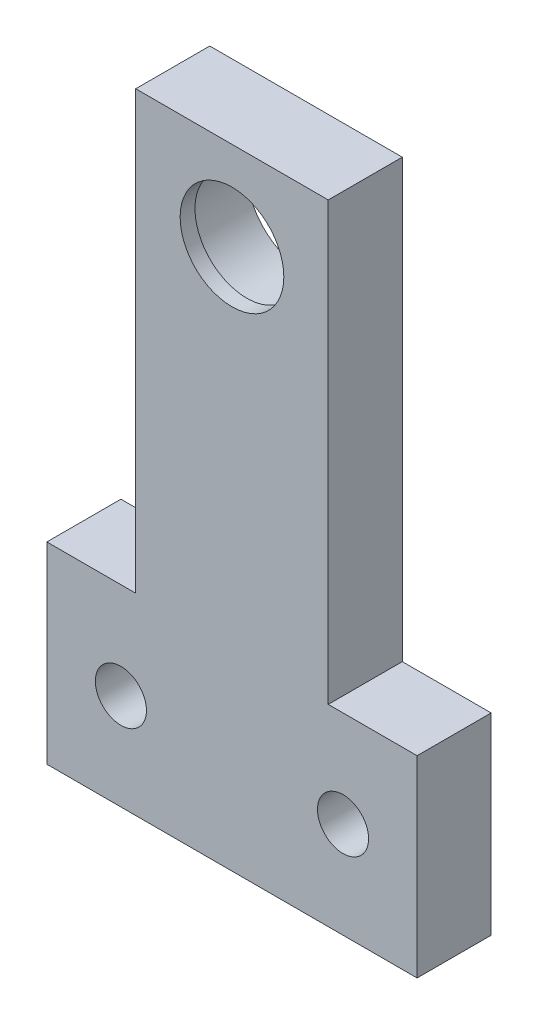
from build123d import *

# Parameters (mm, degrees)
SKETCH_1_R          = 7
SKETCH_1_R_2        = 3.45
EXTRUDE_1_DEPTH     = 10
SKETCH_2_R          = 8.05
SKETCH_2_R_2        = 4
CUT_EXTRUDE_1_DEPTH = 8


with BuildPart() as part:
    # 草图1 → 凸台-拉伸1 (new body)
    with BuildSketch(Plane.XY):
        Polygon((-25, 0), (25, 0), (25, 26), (13, 26), (13, 85), (-13, 85), (-13, 26), (-25, 26), align=None)
        with Locations((0, 73)):
            Circle(SKETCH_1_R, mode=Mode.SUBTRACT)
        with Locations((-15, 13)):
            Circle(SKETCH_1_R_2, mode=Mode.SUBTRACT)
        with Locations((15, 13)):
            Circle(SKETCH_1_R_2, mode=Mode.SUBTRACT)
    extrude(amount=EXTRUDE_1_DEPTH)

    # 草图2 → 切除-拉伸1 (cut)
    with BuildSketch(Plane(origin=(0, 0, 0), x_dir=(-1, 0, 0), z_dir=(0, 0, -1))):
        with Locations((0, 73)):
            Circle(SKETCH_2_R)
        with Locations((0, 73)):
            Circle(SKETCH_2_R_2, mode=Mode.SUBTRACT)
    extrude(amount=-CUT_EXTRUDE_1_DEPTH, mode=Mode.SUBTRACT)


solid = part.part
